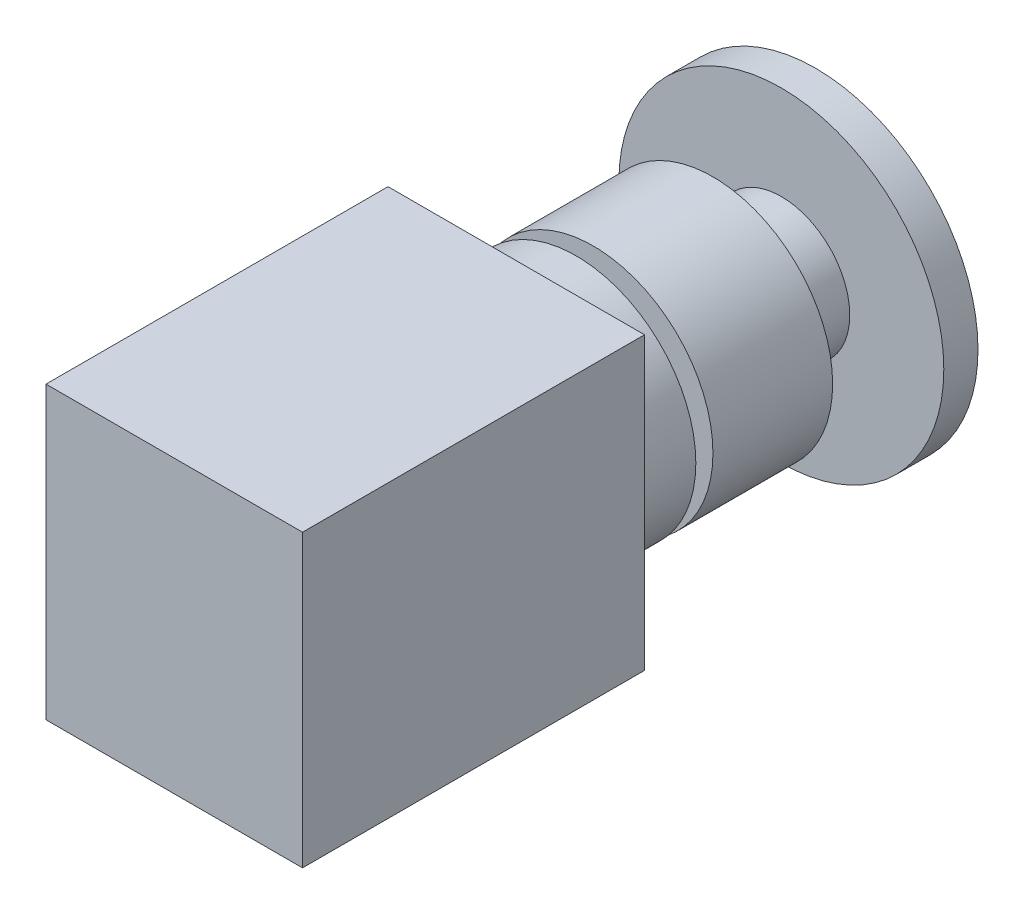
from build123d import *

# Parameters (mm, degrees)
SKETCH_1_R      = 19
EXTRUDE_1_DEPTH = 4
SKETCH_2_R      = 8
EXTRUDE_2_DEPTH = 8
SKETCH_3_R      = 14
EXTRUDE_3_DEPTH = 14
SKETCH_4_R      = 11
EXTRUDE_4_DEPTH = 2
SKETCH_5_R      = 14
EXTRUDE_5_DEPTH = 7
SKETCH_6_W      = 30
SKETCH_6_H      = 34
EXTRUDE_6_DEPTH = 40


with BuildPart() as part:
    # 草图1 → 凸台-拉伸1 (new body)
    with BuildSketch(Plane.XY):
        Circle(SKETCH_1_R)
    extrude(amount=EXTRUDE_1_DEPTH)

    # 草图2 → 凸台-拉伸2 (add)
    with BuildSketch(Plane.XY.offset(4)):
        Circle(SKETCH_2_R)
    extrude(amount=EXTRUDE_2_DEPTH)

    # 草图3 → 凸台-拉伸3 (add)
    with BuildSketch(Plane.XY.offset(12)):
        Circle(SKETCH_3_R)
    extrude(amount=EXTRUDE_3_DEPTH)

    # 草图4 → 凸台-拉伸4 (add)
    with BuildSketch(Plane.XY.offset(26)):
        Circle(SKETCH_4_R)
    extrude(amount=EXTRUDE_4_DEPTH)

    # 草图5 → 凸台-拉伸5 (add)
    with BuildSketch(Plane.XY.offset(28)):
        Circle(SKETCH_5_R)
    extrude(amount=EXTRUDE_5_DEPTH)

    # 草图6 → 凸台-拉伸6 (add)
    with BuildSketch(Plane.XY.offset(35)):
        Rectangle(SKETCH_6_W, SKETCH_6_H)
    extrude(amount=EXTRUDE_6_DEPTH)


solid = part.part
